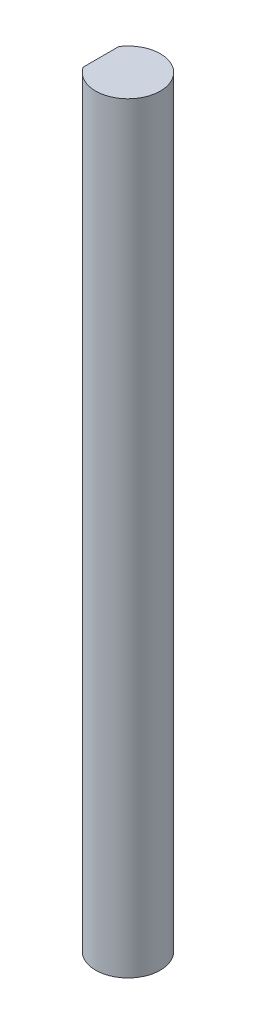
from build123d import *

# Parameters (mm, degrees)
BOSS_EXTRUDE1_DEPTH = 35.3


with BuildPart() as part:
    # Sketch1 → Boss-Extrude1 (new body)
    with BuildSketch(Plane(origin=(0, 0, 0), x_dir=(1, 0, 0), z_dir=(0, 1, 0))):
        with BuildLine():
            Line((-1.25, -0.829156198), (-1.25, 0.829156198))
            ThreePointArc((-1.25, 0.829156198), (1.5, 0), (-1.25, -0.829156198))
        make_face()
    extrude(amount=BOSS_EXTRUDE1_DEPTH)


solid = part.part
